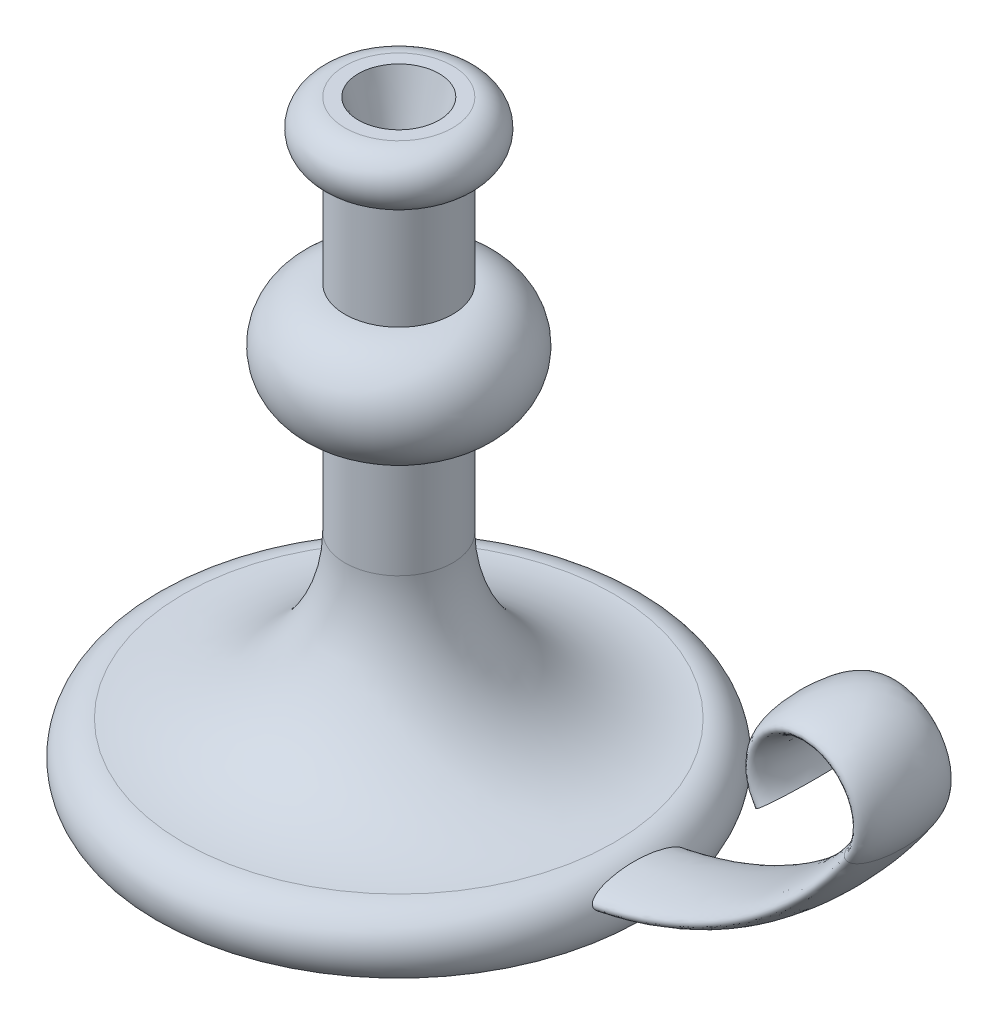
from build123d import *

# Parameters (mm, degrees)
SKETCH3_RX         = 17.5
SKETCH3_RY         = 5
SKETCH4_R          = 15
CUT_EXTRUDE1_DEPTH = 25
CUT_EXTRUDE1_TAPER = 15


with BuildPart() as part:
    # Sketch1 → Revolve1 (revolve)
    with BuildSketch(Plane.XY):
        with BuildLine():
            Line((0, 0), (0, 220))
            Line((0, 220), (20, 220))
            ThreePointArc((20, 220), (30, 210), (20, 200))
            Line((20, 200), (20, 160))
            ThreePointArc((20, 160), (40, 140), (20, 120))
            Line((20, 120), (20, 80))
            ThreePointArc((20, 80), (37.573593129, 37.573593129), (80, 20))
            ThreePointArc((80, 20), (91.180339887, 13.090169944), (90, 0))
            Line((90, 0), (0, 0))
        make_face()
    revolve(axis=Axis((0, 0, 0), (0, 1, 0)))

    # Sweep1: sweep along a path in Sketch2
    with BuildLine(Plane.XY) as sweep1_path:
        Line((0, 10), (60, 10))
        ThreePointArc((60, 10), (129.821200219, 27.240819526), (183.592070943, 75))
        ThreePointArc((183.592070943, 75), (167.113128151, 106.333333333), (150.634185358, 75))
    # Sketch3 → Sweep1 (sweep)
    with BuildSketch(Plane(origin=(0, 0, 0), x_dir=(0, 0, -1), z_dir=(1, 0, 0))):
        with Locations((0, 10)):
            Ellipse(SKETCH3_RX, SKETCH3_RY)
    sweep(path=sweep1_path.line)

    # Sketch4 → Cut-Extrude1 (cut)
    with BuildSketch(Plane(origin=(0, 220, 0), x_dir=(1, 0, 0), z_dir=(0, 1, 0))):
        Circle(SKETCH4_R)
    extrude(amount=-CUT_EXTRUDE1_DEPTH, taper=CUT_EXTRUDE1_TAPER, mode=Mode.SUBTRACT)


solid = part.part
